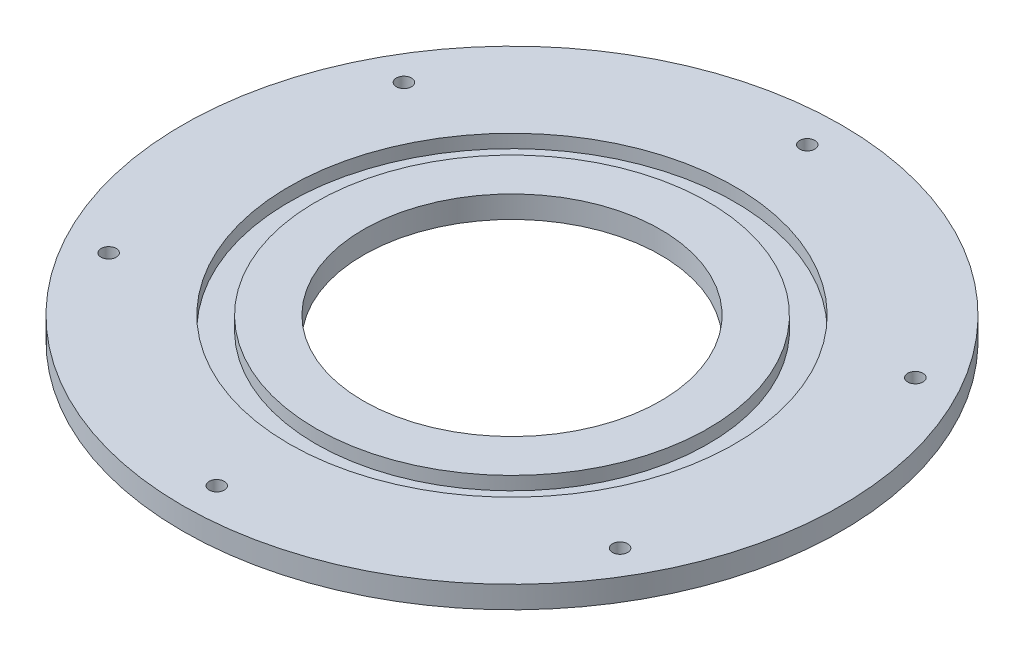
from build123d import *

# Parameters (mm, degrees)
SKETCH1_R           = 86.5
SKETCH1_R_2         = 39
BOSS_EXTRUDE1_DEPTH = 5.8
SKETCH2_R           = 58.5
SKETCH2_R_2         = 51.5
CUT_EXTRUDE1_DEPTH  = 3.5
SKETCH3_R           = 2
CUT_EXTRUDE2_DEPTH  = 6.8


with BuildPart() as part:
    # Sketch1 → Boss-Extrude1 (new body)
    with BuildSketch(Plane(origin=(0, 0, 0), x_dir=(1, 0, 0), z_dir=(0, 1, 0))):
        Circle(SKETCH1_R)
        Circle(SKETCH1_R_2, mode=Mode.SUBTRACT)
    extrude(amount=BOSS_EXTRUDE1_DEPTH)

    # Sketch2 → Cut-Extrude1 (cut)
    with BuildSketch(Plane(origin=(0, 5.8, 0), x_dir=(1, 0, 0), z_dir=(0, 1, 0))):
        Circle(SKETCH2_R)
        Circle(SKETCH2_R_2, mode=Mode.SUBTRACT)
    extrude(amount=-CUT_EXTRUDE1_DEPTH, mode=Mode.SUBTRACT)

    # Sketch3 → Cut-Extrude2 (cut, through all)
    with BuildSketch(Plane(origin=(0, 5.8, 0), x_dir=(1, 0, 0), z_dir=(0, 1, 0))):
        with Locations((0, 77.5)):
            Circle(SKETCH3_R)
        with Locations((67.116968793, 38.75)):
            Circle(SKETCH3_R)
        with Locations((67.116968793, -38.75)):
            Circle(SKETCH3_R)
        with Locations((0, -77.5)):
            Circle(SKETCH3_R)
        with Locations((-67.116968793, -38.75)):
            Circle(SKETCH3_R)
        with Locations((-67.116968793, 38.75)):
            Circle(SKETCH3_R)
    extrude(amount=-CUT_EXTRUDE2_DEPTH, mode=Mode.SUBTRACT)


solid = part.part
